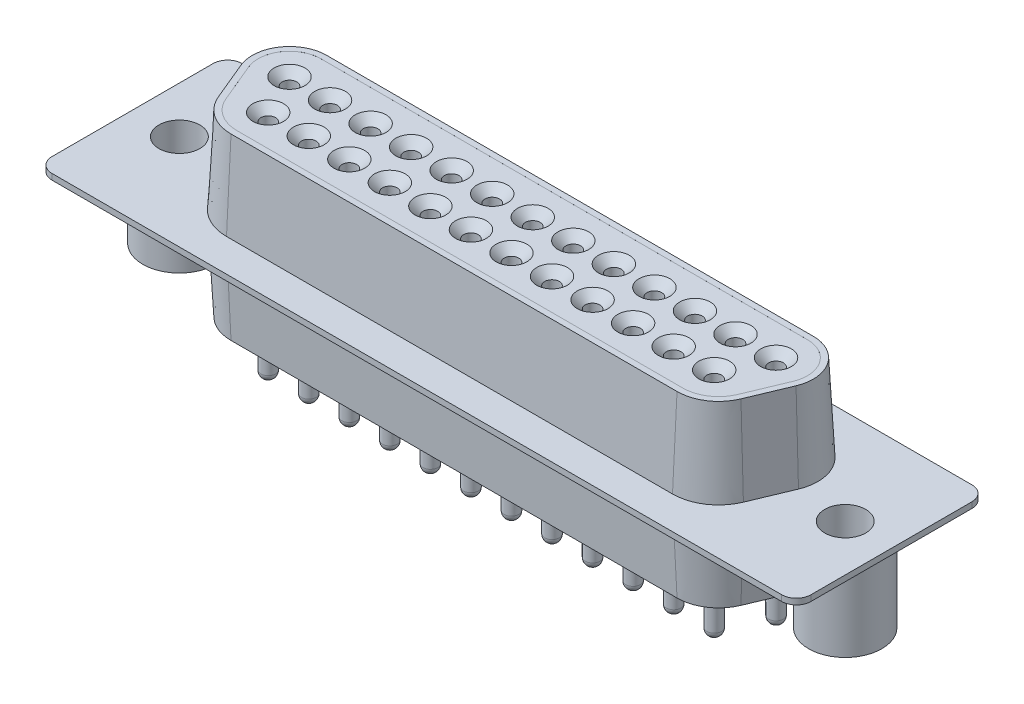
from build123d import *

# Parameters (mm, degrees)
BASE_EXTRUDE_DEPTH            = 5.91
BASE_EXTRUDE_DRAFT            = 3
BOSS_EXTRUDE1_DEPTH           = 0.2
CUT_EXTRUDE1_DEPTH            = 0.001
SKETCH4_R                     = 0.5
CUT_EXTRUDE5_DEPTH            = 6
SKETCH5_R                     = 0.5
BOSS_EXTRUDE5_DEPTH           = 3
DOME3_FACE_RADIUS             = 0.5
DOME3_HEIGHT                  = 0.5
CHAMFER1_SIZE                 = 0.55
LPATTERN1_COUNT               = 13
LPATTERN1_PITCH               = 2.77
LPATTERN1_COPY_1_FACE_RADIUS  = 0.5
LPATTERN1_COPY_1_HEIGHT       = 0.5
LPATTERN1_COPY_2_FACE_RADIUS  = 0.5
LPATTERN1_COPY_2_HEIGHT       = 0.5
LPATTERN1_COPY_3_FACE_RADIUS  = 0.5
LPATTERN1_COPY_3_HEIGHT       = 0.5
LPATTERN1_COPY_4_FACE_RADIUS  = 0.5
LPATTERN1_COPY_4_HEIGHT       = 0.5
LPATTERN1_COPY_5_FACE_RADIUS  = 0.5
LPATTERN1_COPY_5_HEIGHT       = 0.5
LPATTERN1_COPY_6_FACE_RADIUS  = 0.5
LPATTERN1_COPY_6_HEIGHT       = 0.5
LPATTERN1_COPY_7_FACE_RADIUS  = 0.5
LPATTERN1_COPY_7_HEIGHT       = 0.5
LPATTERN1_COPY_8_FACE_RADIUS  = 0.5
LPATTERN1_COPY_8_HEIGHT       = 0.5
LPATTERN1_COPY_9_FACE_RADIUS  = 0.5
LPATTERN1_COPY_9_HEIGHT       = 0.5
LPATTERN1_COPY_10_FACE_RADIUS = 0.5
LPATTERN1_COPY_10_HEIGHT      = 0.5
LPATTERN1_COPY_11_FACE_RADIUS = 0.5
LPATTERN1_COPY_11_HEIGHT      = 0.5
LPATTERN1_COPY_12_FACE_RADIUS = 0.5
LPATTERN1_COPY_12_HEIGHT      = 0.5
CHAMFER1_OF_LPATTERN1_SIZE    = 0.55
SKETCH6_R                     = 0.5
CUT_EXTRUDE8_DEPTH            = 6
SKETCH7_R                     = 0.5
BOSS_EXTRUDE6_DEPTH           = 3
DOME4_FACE_RADIUS             = 0.5
DOME4_HEIGHT                  = 0.5
CHAMFER3_SIZE                 = 0.55
LPATTERN3_COUNT               = 12
LPATTERN3_PITCH               = 2.77
LPATTERN3_COPY_1_FACE_RADIUS  = 0.5
LPATTERN3_COPY_1_HEIGHT       = 0.5
LPATTERN3_COPY_2_FACE_RADIUS  = 0.5
LPATTERN3_COPY_2_HEIGHT       = 0.5
LPATTERN3_COPY_3_FACE_RADIUS  = 0.5
LPATTERN3_COPY_3_HEIGHT       = 0.5
LPATTERN3_COPY_4_FACE_RADIUS  = 0.5
LPATTERN3_COPY_4_HEIGHT       = 0.5
LPATTERN3_COPY_5_FACE_RADIUS  = 0.5
LPATTERN3_COPY_5_HEIGHT       = 0.5
LPATTERN3_COPY_6_FACE_RADIUS  = 0.5
LPATTERN3_COPY_6_HEIGHT       = 0.5
LPATTERN3_COPY_7_FACE_RADIUS  = 0.5
LPATTERN3_COPY_7_HEIGHT       = 0.5
LPATTERN3_COPY_8_FACE_RADIUS  = 0.5
LPATTERN3_COPY_8_HEIGHT       = 0.5
LPATTERN3_COPY_9_FACE_RADIUS  = 0.5
LPATTERN3_COPY_9_HEIGHT       = 0.5
LPATTERN3_COPY_10_FACE_RADIUS = 0.5
LPATTERN3_COPY_10_HEIGHT      = 0.5
LPATTERN3_COPY_11_FACE_RADIUS = 0.5
LPATTERN3_COPY_11_HEIGHT      = 0.5
CHAMFER3_OF_LPATTERN3_SIZE    = 0.55
SKETCH8_R                     = 2.5
BOSS_EXTRUDE4_DEPTH           = 5.9
SKETCH9_R                     = 1.4
CUT_EXTRUDE4_DEPTH            = 45.965403645


with BuildPart() as part:
    # Sketch1 → Base-Extrude (with draft: the straight prism first)
    with BuildSketch(Plane(origin=(0, 0, 0), x_dir=(1, 0, 0), z_dir=(0, 1, 0))):
        with BuildLine():
            ThreePointArc((0, 2.54), (-2.113784333, 1.408373457), (-2.344092715, -0.97817654))
            Line((-2.344092715, -0.97817654), (-1.23595406, -3.633709202))
            ThreePointArc((-1.23595406, -3.633709202), (-0.189716779, -4.9034439), (1.385, -5.38))
            Line((1.385, -5.38), (31.855, -5.38))
            ThreePointArc((31.855, -5.38), (33.429716779, -4.9034439), (34.47595406, -3.633709202))
            Line((34.47595406, -3.633709202), (35.584092715, -0.97817654))
            ThreePointArc((35.584092715, -0.97817654), (35.353784333, 1.408373457), (33.24, 2.54))
            Line((33.24, 2.54), (0, 2.54))
        make_face()
    extrude(amount=-BASE_EXTRUDE_DEPTH)
    # Base-Extrude: the draft: its side faces are tilted about the plane it starts from
    base_extrude_sides = [part.faces().sort_by_distance(p)[0] for p in [
        (16.62, -2.955, -2.54),
        (-2.113784333, -2.955, -1.408373457),
        (-1.790023387, -2.955, 2.305942871),
        (-0.189716779, -2.955, 4.9034439),
        (16.62, -2.955, 5.38),
        (33.429716779, -2.955, 4.9034439),
        (35.030023387, -2.955, 2.305942871),
        (35.353784333, -2.955, -1.408373457),
    ]]
    draft(base_extrude_sides, Plane(origin=(0, 0, 0), x_dir=(1, 0, 0), z_dir=(0, 1, 0)), BASE_EXTRUDE_DRAFT)

    # Sketch2 → Boss-Extrude1 (add)
    with BuildSketch(Plane.XZ.offset(5.91)):
        with BuildLine():
            Line((41.545, 7.92), (-8.305, 7.92))
            ThreePointArc((-8.305, 7.92), (-9.012106781, 7.627106781), (-9.305, 6.92))
            Line((-9.305, 6.92), (-9.305, -4.08))
            ThreePointArc((-9.305, -4.08), (-9.012106781, -4.787106781), (-8.305, -5.08))
            Line((-8.305, -5.08), (41.545, -5.08))
            ThreePointArc((41.545, -5.08), (42.252106781, -4.787106781), (42.545, -4.08))
            Line((42.545, -4.08), (42.545, 6.92))
            ThreePointArc((42.545, 6.92), (42.252106781, 7.627106781), (41.545, 7.92))
        make_face()
    extrude(amount=BOSS_EXTRUDE1_DEPTH)

    # Sketch3 → Cut-Extrude1 (cut)
    with BuildSketch(Plane(origin=(0, 0, 0), x_dir=(-1, 0, 0), z_dir=(0, 1, 0))):
        with BuildLine():
            Line((-33.24, -2.14), (0, -2.14))
            ThreePointArc((0, -2.14), (1.78090491, -1.186582362), (1.974944256, 0.82413299))
            Line((1.974944256, 0.82413299), (0.8668056, 3.479665652))
            ThreePointArc((0.8668056, 3.479665652), (-0.032074317, 4.570564477), (-1.385, 4.98))
            Line((-1.385, 4.98), (-31.855, 4.98))
            ThreePointArc((-31.855, 4.98), (-33.207925683, 4.570564477), (-34.1068056, 3.479665652))
            Line((-34.1068056, 3.479665652), (-35.214944256, 0.82413299))
            ThreePointArc((-35.214944256, 0.82413299), (-35.02090491, -1.186582362), (-33.24, -2.14))
        make_face()
    extrude(amount=-CUT_EXTRUDE1_DEPTH, mode=Mode.SUBTRACT)

    # Boss-Mirror1: part across plane


with BuildPart() as part_1:
    add(part.part)
    add(part.part.mirror(Plane(origin=(41.545, -6.11, 6.92), x_dir=(0, 0, 1), z_dir=(0, -1, 0))))

    # Sketch4 → Cut-Extrude5 (cut)
    with BuildSketch(Plane(origin=(0, -0.001, 0), x_dir=(-1, 0, 0), z_dir=(0, 1, 0))):
        with Locations(Location((0, 0, 0), (0, 0, 90))):
            Circle(SKETCH4_R)
    cut_extrude5 = extrude(amount=-CUT_EXTRUDE5_DEPTH, mode=Mode.SUBTRACT)

    # Sketch5 → Boss-Extrude5 (add)
    with BuildSketch(Plane.XZ.offset(12.219)):
        with Locations(Location((0, 0, 0), (0, 0, 90))):
            Circle(SKETCH5_R)
    boss_extrude5 = extrude(amount=BOSS_EXTRUDE5_DEPTH)

    # Dome3: a dome of height H over a round flat face of radius A is a cap of a sphere of radius (A * A + H * H) / (2 * H)
    dome3_r = (DOME3_FACE_RADIUS * DOME3_FACE_RADIUS + DOME3_HEIGHT * DOME3_HEIGHT) / (2 * DOME3_HEIGHT)
    dome3_base = Plane((0, -15.219, 0), z_dir=(0, -1, 0))
    with Locations(dome3_base.offset(DOME3_HEIGHT - dome3_r)):
        dome3_ball = Sphere(dome3_r, mode=Mode.PRIVATE)
    add(split(dome3_ball, bisect_by=dome3_base, keep=Keep.TOP, mode=Mode.PRIVATE))

    # Chamfer1
    chamfer1_edges = [part_1.edges().sort_by_distance(p)[0] for p in [
        (0, -0.001, -0.5),
    ]]
    chamfer(chamfer1_edges, length=CHAMFER1_SIZE)

    # LPattern1: Cut-Extrude5, Boss-Extrude5 ×13
    with Locations(*[(i * LPATTERN1_PITCH, 0, 0) for i in range(1, LPATTERN1_COUNT)]):
        add(cut_extrude5, mode=Mode.SUBTRACT)
        add(boss_extrude5)

    # LPattern1 copy 1: a dome of height H over a round flat face of radius A is a cap of a sphere of radius (A * A + H * H) / (2 * H)
    lpattern1_copy_1_r = (LPATTERN1_COPY_1_FACE_RADIUS * LPATTERN1_COPY_1_FACE_RADIUS + LPATTERN1_COPY_1_HEIGHT * LPATTERN1_COPY_1_HEIGHT) / (2 * LPATTERN1_COPY_1_HEIGHT)
    lpattern1_copy_1_base = Plane((2.77, -15.219, 0), z_dir=(0, -1, 0))
    with Locations(lpattern1_copy_1_base.offset(LPATTERN1_COPY_1_HEIGHT - lpattern1_copy_1_r)):
        lpattern1_copy_1_ball = Sphere(lpattern1_copy_1_r, mode=Mode.PRIVATE)
    add(split(lpattern1_copy_1_ball, bisect_by=lpattern1_copy_1_base, keep=Keep.TOP, mode=Mode.PRIVATE))

    # LPattern1 copy 2: a dome of height H over a round flat face of radius A is a cap of a sphere of radius (A * A + H * H) / (2 * H)
    lpattern1_copy_2_r = (LPATTERN1_COPY_2_FACE_RADIUS * LPATTERN1_COPY_2_FACE_RADIUS + LPATTERN1_COPY_2_HEIGHT * LPATTERN1_COPY_2_HEIGHT) / (2 * LPATTERN1_COPY_2_HEIGHT)
    lpattern1_copy_2_base = Plane((5.54, -15.219, 0), z_dir=(0, -1, 0))
    with Locations(lpattern1_copy_2_base.offset(LPATTERN1_COPY_2_HEIGHT - lpattern1_copy_2_r)):
        lpattern1_copy_2_ball = Sphere(lpattern1_copy_2_r, mode=Mode.PRIVATE)
    add(split(lpattern1_copy_2_ball, bisect_by=lpattern1_copy_2_base, keep=Keep.TOP, mode=Mode.PRIVATE))

    # LPattern1 copy 3: a dome of height H over a round flat face of radius A is a cap of a sphere of radius (A * A + H * H) / (2 * H)
    lpattern1_copy_3_r = (LPATTERN1_COPY_3_FACE_RADIUS * LPATTERN1_COPY_3_FACE_RADIUS + LPATTERN1_COPY_3_HEIGHT * LPATTERN1_COPY_3_HEIGHT) / (2 * LPATTERN1_COPY_3_HEIGHT)
    lpattern1_copy_3_base = Plane((8.31, -15.219, 0), z_dir=(0, -1, 0))
    with Locations(lpattern1_copy_3_base.offset(LPATTERN1_COPY_3_HEIGHT - lpattern1_copy_3_r)):
        lpattern1_copy_3_ball = Sphere(lpattern1_copy_3_r, mode=Mode.PRIVATE)
    add(split(lpattern1_copy_3_ball, bisect_by=lpattern1_copy_3_base, keep=Keep.TOP, mode=Mode.PRIVATE))

    # LPattern1 copy 4: a dome of height H over a round flat face of radius A is a cap of a sphere of radius (A * A + H * H) / (2 * H)
    lpattern1_copy_4_r = (LPATTERN1_COPY_4_FACE_RADIUS * LPATTERN1_COPY_4_FACE_RADIUS + LPATTERN1_COPY_4_HEIGHT * LPATTERN1_COPY_4_HEIGHT) / (2 * LPATTERN1_COPY_4_HEIGHT)
    lpattern1_copy_4_base = Plane((11.08, -15.219, 0), z_dir=(0, -1, 0))
    with Locations(lpattern1_copy_4_base.offset(LPATTERN1_COPY_4_HEIGHT - lpattern1_copy_4_r)):
        lpattern1_copy_4_ball = Sphere(lpattern1_copy_4_r, mode=Mode.PRIVATE)
    add(split(lpattern1_copy_4_ball, bisect_by=lpattern1_copy_4_base, keep=Keep.TOP, mode=Mode.PRIVATE))

    # LPattern1 copy 5: a dome of height H over a round flat face of radius A is a cap of a sphere of radius (A * A + H * H) / (2 * H)
    lpattern1_copy_5_r = (LPATTERN1_COPY_5_FACE_RADIUS * LPATTERN1_COPY_5_FACE_RADIUS + LPATTERN1_COPY_5_HEIGHT * LPATTERN1_COPY_5_HEIGHT) / (2 * LPATTERN1_COPY_5_HEIGHT)
    lpattern1_copy_5_base = Plane((13.85, -15.219, 0), z_dir=(0, -1, 0))
    with Locations(lpattern1_copy_5_base.offset(LPATTERN1_COPY_5_HEIGHT - lpattern1_copy_5_r)):
        lpattern1_copy_5_ball = Sphere(lpattern1_copy_5_r, mode=Mode.PRIVATE)
    add(split(lpattern1_copy_5_ball, bisect_by=lpattern1_copy_5_base, keep=Keep.TOP, mode=Mode.PRIVATE))

    # LPattern1 copy 6: a dome of height H over a round flat face of radius A is a cap of a sphere of radius (A * A + H * H) / (2 * H)
    lpattern1_copy_6_r = (LPATTERN1_COPY_6_FACE_RADIUS * LPATTERN1_COPY_6_FACE_RADIUS + LPATTERN1_COPY_6_HEIGHT * LPATTERN1_COPY_6_HEIGHT) / (2 * LPATTERN1_COPY_6_HEIGHT)
    lpattern1_copy_6_base = Plane((16.62, -15.219, 0), z_dir=(0, -1, 0))
    with Locations(lpattern1_copy_6_base.offset(LPATTERN1_COPY_6_HEIGHT - lpattern1_copy_6_r)):
        lpattern1_copy_6_ball = Sphere(lpattern1_copy_6_r, mode=Mode.PRIVATE)
    add(split(lpattern1_copy_6_ball, bisect_by=lpattern1_copy_6_base, keep=Keep.TOP, mode=Mode.PRIVATE))

    # LPattern1 copy 7: a dome of height H over a round flat face of radius A is a cap of a sphere of radius (A * A + H * H) / (2 * H)
    lpattern1_copy_7_r = (LPATTERN1_COPY_7_FACE_RADIUS * LPATTERN1_COPY_7_FACE_RADIUS + LPATTERN1_COPY_7_HEIGHT * LPATTERN1_COPY_7_HEIGHT) / (2 * LPATTERN1_COPY_7_HEIGHT)
    lpattern1_copy_7_base = Plane((19.39, -15.219, 0), z_dir=(0, -1, 0))
    with Locations(lpattern1_copy_7_base.offset(LPATTERN1_COPY_7_HEIGHT - lpattern1_copy_7_r)):
        lpattern1_copy_7_ball = Sphere(lpattern1_copy_7_r, mode=Mode.PRIVATE)
    add(split(lpattern1_copy_7_ball, bisect_by=lpattern1_copy_7_base, keep=Keep.TOP, mode=Mode.PRIVATE))

    # LPattern1 copy 8: a dome of height H over a round flat face of radius A is a cap of a sphere of radius (A * A + H * H) / (2 * H)
    lpattern1_copy_8_r = (LPATTERN1_COPY_8_FACE_RADIUS * LPATTERN1_COPY_8_FACE_RADIUS + LPATTERN1_COPY_8_HEIGHT * LPATTERN1_COPY_8_HEIGHT) / (2 * LPATTERN1_COPY_8_HEIGHT)
    lpattern1_copy_8_base = Plane((22.16, -15.219, 0), z_dir=(0, -1, 0))
    with Locations(lpattern1_copy_8_base.offset(LPATTERN1_COPY_8_HEIGHT - lpattern1_copy_8_r)):
        lpattern1_copy_8_ball = Sphere(lpattern1_copy_8_r, mode=Mode.PRIVATE)
    add(split(lpattern1_copy_8_ball, bisect_by=lpattern1_copy_8_base, keep=Keep.TOP, mode=Mode.PRIVATE))

    # LPattern1 copy 9: a dome of height H over a round flat face of radius A is a cap of a sphere of radius (A * A + H * H) / (2 * H)
    lpattern1_copy_9_r = (LPATTERN1_COPY_9_FACE_RADIUS * LPATTERN1_COPY_9_FACE_RADIUS + LPATTERN1_COPY_9_HEIGHT * LPATTERN1_COPY_9_HEIGHT) / (2 * LPATTERN1_COPY_9_HEIGHT)
    lpattern1_copy_9_base = Plane((24.93, -15.219, 0), z_dir=(0, -1, 0))
    with Locations(lpattern1_copy_9_base.offset(LPATTERN1_COPY_9_HEIGHT - lpattern1_copy_9_r)):
        lpattern1_copy_9_ball = Sphere(lpattern1_copy_9_r, mode=Mode.PRIVATE)
    add(split(lpattern1_copy_9_ball, bisect_by=lpattern1_copy_9_base, keep=Keep.TOP, mode=Mode.PRIVATE))

    # LPattern1 copy 10: a dome of height H over a round flat face of radius A is a cap of a sphere of radius (A * A + H * H) / (2 * H)
    lpattern1_copy_10_r = (LPATTERN1_COPY_10_FACE_RADIUS * LPATTERN1_COPY_10_FACE_RADIUS + LPATTERN1_COPY_10_HEIGHT * LPATTERN1_COPY_10_HEIGHT) / (2 * LPATTERN1_COPY_10_HEIGHT)
    lpattern1_copy_10_base = Plane((27.7, -15.219, 0), z_dir=(0, -1, 0))
    with Locations(lpattern1_copy_10_base.offset(LPATTERN1_COPY_10_HEIGHT - lpattern1_copy_10_r)):
        lpattern1_copy_10_ball = Sphere(lpattern1_copy_10_r, mode=Mode.PRIVATE)
    add(split(lpattern1_copy_10_ball, bisect_by=lpattern1_copy_10_base, keep=Keep.TOP, mode=Mode.PRIVATE))

    # LPattern1 copy 11: a dome of height H over a round flat face of radius A is a cap of a sphere of radius (A * A + H * H) / (2 * H)
    lpattern1_copy_11_r = (LPATTERN1_COPY_11_FACE_RADIUS * LPATTERN1_COPY_11_FACE_RADIUS + LPATTERN1_COPY_11_HEIGHT * LPATTERN1_COPY_11_HEIGHT) / (2 * LPATTERN1_COPY_11_HEIGHT)
    lpattern1_copy_11_base = Plane((30.47, -15.219, 0), z_dir=(0, -1, 0))
    with Locations(lpattern1_copy_11_base.offset(LPATTERN1_COPY_11_HEIGHT - lpattern1_copy_11_r)):
        lpattern1_copy_11_ball = Sphere(lpattern1_copy_11_r, mode=Mode.PRIVATE)
    add(split(lpattern1_copy_11_ball, bisect_by=lpattern1_copy_11_base, keep=Keep.TOP, mode=Mode.PRIVATE))

    # LPattern1 copy 12: a dome of height H over a round flat face of radius A is a cap of a sphere of radius (A * A + H * H) / (2 * H)
    lpattern1_copy_12_r = (LPATTERN1_COPY_12_FACE_RADIUS * LPATTERN1_COPY_12_FACE_RADIUS + LPATTERN1_COPY_12_HEIGHT * LPATTERN1_COPY_12_HEIGHT) / (2 * LPATTERN1_COPY_12_HEIGHT)
    lpattern1_copy_12_base = Plane((33.24, -15.219, 0), z_dir=(0, -1, 0))
    with Locations(lpattern1_copy_12_base.offset(LPATTERN1_COPY_12_HEIGHT - lpattern1_copy_12_r)):
        lpattern1_copy_12_ball = Sphere(lpattern1_copy_12_r, mode=Mode.PRIVATE)
    add(split(lpattern1_copy_12_ball, bisect_by=lpattern1_copy_12_base, keep=Keep.TOP, mode=Mode.PRIVATE))

    # Chamfer1 of LPattern1
    chamfer1_of_lpattern1_edges = [part_1.edges().sort_by_distance(p)[0] for p in [
        (2.77, -0.001, -0.5),
        (5.54, -0.001, -0.5),
        (8.31, -0.001, -0.5),
        (11.08, -0.001, -0.5),
        (13.85, -0.001, -0.5),
        (16.62, -0.001, -0.5),
        (19.39, -0.001, -0.5),
        (22.16, -0.001, -0.5),
        (24.93, -0.001, -0.5),
        (27.7, -0.001, -0.5),
        (30.47, -0.001, -0.5),
        (33.24, -0.001, -0.5),
    ]]
    chamfer(chamfer1_of_lpattern1_edges, length=CHAMFER1_OF_LPATTERN1_SIZE)

    # Sketch6 → Cut-Extrude8 (cut)
    with BuildSketch(Plane(origin=(0, -0.001, 0), x_dir=(-1, 0, 0), z_dir=(0, 1, 0))):
        with Locations(Location((-1.385, 2.84, 0), (0, 0, 90))):
            Circle(SKETCH6_R)
    cut_extrude8 = extrude(amount=-CUT_EXTRUDE8_DEPTH, mode=Mode.SUBTRACT)

    # Sketch7 → Boss-Extrude6 (add)
    with BuildSketch(Plane.XZ.offset(12.219)):
        with Locations(Location((1.385, 2.84, 0), (0, 0, 90))):
            Circle(SKETCH7_R)
    boss_extrude6 = extrude(amount=BOSS_EXTRUDE6_DEPTH)

    # Dome4: a dome of height H over a round flat face of radius A is a cap of a sphere of radius (A * A + H * H) / (2 * H)
    dome4_r = (DOME4_FACE_RADIUS * DOME4_FACE_RADIUS + DOME4_HEIGHT * DOME4_HEIGHT) / (2 * DOME4_HEIGHT)
    dome4_base = Plane((1.385, -15.219, 2.84), z_dir=(0, -1, 0))
    with Locations(dome4_base.offset(DOME4_HEIGHT - dome4_r)):
        dome4_ball = Sphere(dome4_r, mode=Mode.PRIVATE)
    add(split(dome4_ball, bisect_by=dome4_base, keep=Keep.TOP, mode=Mode.PRIVATE))

    # Chamfer3
    chamfer3_edges = [part_1.edges().sort_by_distance(p)[0] for p in [
        (1.385, -0.001, 2.34),
    ]]
    chamfer(chamfer3_edges, length=CHAMFER3_SIZE)

    # LPattern3: Cut-Extrude8, Boss-Extrude6 ×12
    with Locations(*[(i * LPATTERN3_PITCH, 0, 0) for i in range(1, LPATTERN3_COUNT)]):
        add(cut_extrude8, mode=Mode.SUBTRACT)
        add(boss_extrude6)

    # LPattern3 copy 1: a dome of height H over a round flat face of radius A is a cap of a sphere of radius (A * A + H * H) / (2 * H)
    lpattern3_copy_1_r = (LPATTERN3_COPY_1_FACE_RADIUS * LPATTERN3_COPY_1_FACE_RADIUS + LPATTERN3_COPY_1_HEIGHT * LPATTERN3_COPY_1_HEIGHT) / (2 * LPATTERN3_COPY_1_HEIGHT)
    lpattern3_copy_1_base = Plane((4.155, -15.219, 2.84), z_dir=(0, -1, 0))
    with Locations(lpattern3_copy_1_base.offset(LPATTERN3_COPY_1_HEIGHT - lpattern3_copy_1_r)):
        lpattern3_copy_1_ball = Sphere(lpattern3_copy_1_r, mode=Mode.PRIVATE)
    add(split(lpattern3_copy_1_ball, bisect_by=lpattern3_copy_1_base, keep=Keep.TOP, mode=Mode.PRIVATE))

    # LPattern3 copy 2: a dome of height H over a round flat face of radius A is a cap of a sphere of radius (A * A + H * H) / (2 * H)
    lpattern3_copy_2_r = (LPATTERN3_COPY_2_FACE_RADIUS * LPATTERN3_COPY_2_FACE_RADIUS + LPATTERN3_COPY_2_HEIGHT * LPATTERN3_COPY_2_HEIGHT) / (2 * LPATTERN3_COPY_2_HEIGHT)
    lpattern3_copy_2_base = Plane((6.925, -15.219, 2.84), z_dir=(0, -1, 0))
    with Locations(lpattern3_copy_2_base.offset(LPATTERN3_COPY_2_HEIGHT - lpattern3_copy_2_r)):
        lpattern3_copy_2_ball = Sphere(lpattern3_copy_2_r, mode=Mode.PRIVATE)
    add(split(lpattern3_copy_2_ball, bisect_by=lpattern3_copy_2_base, keep=Keep.TOP, mode=Mode.PRIVATE))

    # LPattern3 copy 3: a dome of height H over a round flat face of radius A is a cap of a sphere of radius (A * A + H * H) / (2 * H)
    lpattern3_copy_3_r = (LPATTERN3_COPY_3_FACE_RADIUS * LPATTERN3_COPY_3_FACE_RADIUS + LPATTERN3_COPY_3_HEIGHT * LPATTERN3_COPY_3_HEIGHT) / (2 * LPATTERN3_COPY_3_HEIGHT)
    lpattern3_copy_3_base = Plane((9.695, -15.219, 2.84), z_dir=(0, -1, 0))
    with Locations(lpattern3_copy_3_base.offset(LPATTERN3_COPY_3_HEIGHT - lpattern3_copy_3_r)):
        lpattern3_copy_3_ball = Sphere(lpattern3_copy_3_r, mode=Mode.PRIVATE)
    add(split(lpattern3_copy_3_ball, bisect_by=lpattern3_copy_3_base, keep=Keep.TOP, mode=Mode.PRIVATE))

    # LPattern3 copy 4: a dome of height H over a round flat face of radius A is a cap of a sphere of radius (A * A + H * H) / (2 * H)
    lpattern3_copy_4_r = (LPATTERN3_COPY_4_FACE_RADIUS * LPATTERN3_COPY_4_FACE_RADIUS + LPATTERN3_COPY_4_HEIGHT * LPATTERN3_COPY_4_HEIGHT) / (2 * LPATTERN3_COPY_4_HEIGHT)
    lpattern3_copy_4_base = Plane((12.465, -15.219, 2.84), z_dir=(0, -1, 0))
    with Locations(lpattern3_copy_4_base.offset(LPATTERN3_COPY_4_HEIGHT - lpattern3_copy_4_r)):
        lpattern3_copy_4_ball = Sphere(lpattern3_copy_4_r, mode=Mode.PRIVATE)
    add(split(lpattern3_copy_4_ball, bisect_by=lpattern3_copy_4_base, keep=Keep.TOP, mode=Mode.PRIVATE))

    # LPattern3 copy 5: a dome of height H over a round flat face of radius A is a cap of a sphere of radius (A * A + H * H) / (2 * H)
    lpattern3_copy_5_r = (LPATTERN3_COPY_5_FACE_RADIUS * LPATTERN3_COPY_5_FACE_RADIUS + LPATTERN3_COPY_5_HEIGHT * LPATTERN3_COPY_5_HEIGHT) / (2 * LPATTERN3_COPY_5_HEIGHT)
    lpattern3_copy_5_base = Plane((15.235, -15.219, 2.84), z_dir=(0, -1, 0))
    with Locations(lpattern3_copy_5_base.offset(LPATTERN3_COPY_5_HEIGHT - lpattern3_copy_5_r)):
        lpattern3_copy_5_ball = Sphere(lpattern3_copy_5_r, mode=Mode.PRIVATE)
    add(split(lpattern3_copy_5_ball, bisect_by=lpattern3_copy_5_base, keep=Keep.TOP, mode=Mode.PRIVATE))

    # LPattern3 copy 6: a dome of height H over a round flat face of radius A is a cap of a sphere of radius (A * A + H * H) / (2 * H)
    lpattern3_copy_6_r = (LPATTERN3_COPY_6_FACE_RADIUS * LPATTERN3_COPY_6_FACE_RADIUS + LPATTERN3_COPY_6_HEIGHT * LPATTERN3_COPY_6_HEIGHT) / (2 * LPATTERN3_COPY_6_HEIGHT)
    lpattern3_copy_6_base = Plane((18.005, -15.219, 2.84), z_dir=(0, -1, 0))
    with Locations(lpattern3_copy_6_base.offset(LPATTERN3_COPY_6_HEIGHT - lpattern3_copy_6_r)):
        lpattern3_copy_6_ball = Sphere(lpattern3_copy_6_r, mode=Mode.PRIVATE)
    add(split(lpattern3_copy_6_ball, bisect_by=lpattern3_copy_6_base, keep=Keep.TOP, mode=Mode.PRIVATE))

    # LPattern3 copy 7: a dome of height H over a round flat face of radius A is a cap of a sphere of radius (A * A + H * H) / (2 * H)
    lpattern3_copy_7_r = (LPATTERN3_COPY_7_FACE_RADIUS * LPATTERN3_COPY_7_FACE_RADIUS + LPATTERN3_COPY_7_HEIGHT * LPATTERN3_COPY_7_HEIGHT) / (2 * LPATTERN3_COPY_7_HEIGHT)
    lpattern3_copy_7_base = Plane((20.775, -15.219, 2.84), z_dir=(0, -1, 0))
    with Locations(lpattern3_copy_7_base.offset(LPATTERN3_COPY_7_HEIGHT - lpattern3_copy_7_r)):
        lpattern3_copy_7_ball = Sphere(lpattern3_copy_7_r, mode=Mode.PRIVATE)
    add(split(lpattern3_copy_7_ball, bisect_by=lpattern3_copy_7_base, keep=Keep.TOP, mode=Mode.PRIVATE))

    # LPattern3 copy 8: a dome of height H over a round flat face of radius A is a cap of a sphere of radius (A * A + H * H) / (2 * H)
    lpattern3_copy_8_r = (LPATTERN3_COPY_8_FACE_RADIUS * LPATTERN3_COPY_8_FACE_RADIUS + LPATTERN3_COPY_8_HEIGHT * LPATTERN3_COPY_8_HEIGHT) / (2 * LPATTERN3_COPY_8_HEIGHT)
    lpattern3_copy_8_base = Plane((23.545, -15.219, 2.84), z_dir=(0, -1, 0))
    with Locations(lpattern3_copy_8_base.offset(LPATTERN3_COPY_8_HEIGHT - lpattern3_copy_8_r)):
        lpattern3_copy_8_ball = Sphere(lpattern3_copy_8_r, mode=Mode.PRIVATE)
    add(split(lpattern3_copy_8_ball, bisect_by=lpattern3_copy_8_base, keep=Keep.TOP, mode=Mode.PRIVATE))

    # LPattern3 copy 9: a dome of height H over a round flat face of radius A is a cap of a sphere of radius (A * A + H * H) / (2 * H)
    lpattern3_copy_9_r = (LPATTERN3_COPY_9_FACE_RADIUS * LPATTERN3_COPY_9_FACE_RADIUS + LPATTERN3_COPY_9_HEIGHT * LPATTERN3_COPY_9_HEIGHT) / (2 * LPATTERN3_COPY_9_HEIGHT)
    lpattern3_copy_9_base = Plane((26.315, -15.219, 2.84), z_dir=(0, -1, 0))
    with Locations(lpattern3_copy_9_base.offset(LPATTERN3_COPY_9_HEIGHT - lpattern3_copy_9_r)):
        lpattern3_copy_9_ball = Sphere(lpattern3_copy_9_r, mode=Mode.PRIVATE)
    add(split(lpattern3_copy_9_ball, bisect_by=lpattern3_copy_9_base, keep=Keep.TOP, mode=Mode.PRIVATE))

    # LPattern3 copy 10: a dome of height H over a round flat face of radius A is a cap of a sphere of radius (A * A + H * H) / (2 * H)
    lpattern3_copy_10_r = (LPATTERN3_COPY_10_FACE_RADIUS * LPATTERN3_COPY_10_FACE_RADIUS + LPATTERN3_COPY_10_HEIGHT * LPATTERN3_COPY_10_HEIGHT) / (2 * LPATTERN3_COPY_10_HEIGHT)
    lpattern3_copy_10_base = Plane((29.085, -15.219, 2.84), z_dir=(0, -1, 0))
    with Locations(lpattern3_copy_10_base.offset(LPATTERN3_COPY_10_HEIGHT - lpattern3_copy_10_r)):
        lpattern3_copy_10_ball = Sphere(lpattern3_copy_10_r, mode=Mode.PRIVATE)
    add(split(lpattern3_copy_10_ball, bisect_by=lpattern3_copy_10_base, keep=Keep.TOP, mode=Mode.PRIVATE))

    # LPattern3 copy 11: a dome of height H over a round flat face of radius A is a cap of a sphere of radius (A * A + H * H) / (2 * H)
    lpattern3_copy_11_r = (LPATTERN3_COPY_11_FACE_RADIUS * LPATTERN3_COPY_11_FACE_RADIUS + LPATTERN3_COPY_11_HEIGHT * LPATTERN3_COPY_11_HEIGHT) / (2 * LPATTERN3_COPY_11_HEIGHT)
    lpattern3_copy_11_base = Plane((31.855, -15.219, 2.84), z_dir=(0, -1, 0))
    with Locations(lpattern3_copy_11_base.offset(LPATTERN3_COPY_11_HEIGHT - lpattern3_copy_11_r)):
        lpattern3_copy_11_ball = Sphere(lpattern3_copy_11_r, mode=Mode.PRIVATE)
    add(split(lpattern3_copy_11_ball, bisect_by=lpattern3_copy_11_base, keep=Keep.TOP, mode=Mode.PRIVATE))

    # Chamfer3 of LPattern3
    chamfer3_of_lpattern3_edges = [part_1.edges().sort_by_distance(p)[0] for p in [
        (4.155, -0.001, 2.34),
        (6.925, -0.001, 2.34),
        (9.695, -0.001, 2.34),
        (12.465, -0.001, 2.34),
        (15.235, -0.001, 2.34),
        (18.005, -0.001, 2.34),
        (20.775, -0.001, 2.34),
        (23.545, -0.001, 2.34),
        (26.315, -0.001, 2.34),
        (29.085, -0.001, 2.34),
        (31.855, -0.001, 2.34),
    ]]
    chamfer(chamfer3_of_lpattern3_edges, length=CHAMFER3_OF_LPATTERN3_SIZE)

    # Sketch8 → Boss-Extrude4 (add)
    with BuildSketch(Plane(origin=(0, -6.31, 0), x_dir=(-1, 0, 0), z_dir=(0, 1, 0))):
        with Locations(Location((-39.365, 1.4, 0), (0, 0, 90))):
            Circle(SKETCH8_R)
    boss_extrude4 = extrude(amount=-BOSS_EXTRUDE4_DEPTH)

    # Sketch9 → Cut-Extrude4 (cut, through all)
    with BuildSketch(Plane.XZ.offset(12.21)):
        with Locations(Location((39.365, 1.4, 0), (0, 0, 270))):
            Circle(SKETCH9_R)
    cut_extrude4 = extrude(amount=-CUT_EXTRUDE4_DEPTH, mode=Mode.SUBTRACT)

    # Mirror1: Boss-Extrude4, Cut-Extrude4 across plane
    add(boss_extrude4.mirror(Plane(origin=(16.62, 0, 0), x_dir=(0, 0, 1), z_dir=(1, 0, 0))))
    add(cut_extrude4.mirror(Plane(origin=(16.62, 0, 0), x_dir=(0, 0, 1), z_dir=(1, 0, 0))), mode=Mode.SUBTRACT)


solid = part_1.part
